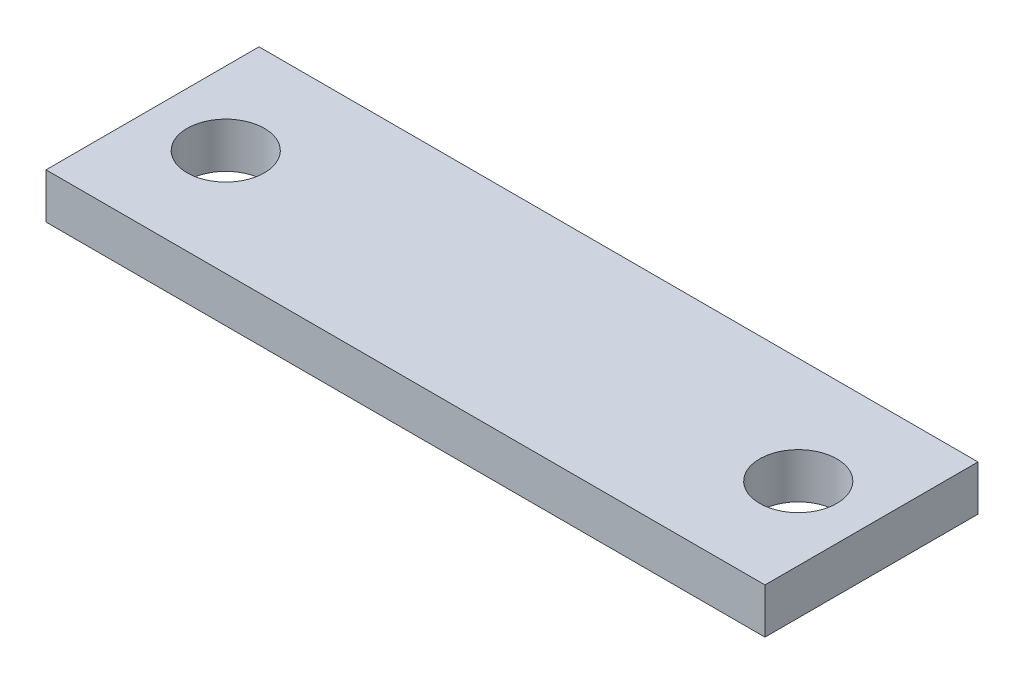
from build123d import *

# Parameters (mm, degrees)
SKETCH1_W           = 27
SKETCH1_H           = 8
SKETCH1_R           = 1.45
BOSS_EXTRUDE1_DEPTH = 1.7


with BuildPart() as part:
    # Sketch1 → Boss-Extrude1 (new body)
    with BuildSketch(Plane(origin=(0, 0, 0), x_dir=(1, 0, 0), z_dir=(0, 1, 0))):
        Rectangle(SKETCH1_W, SKETCH1_H)
        with Locations((-10.75, 0)):
            Circle(SKETCH1_R, mode=Mode.SUBTRACT)
        with Locations((10.75, 0)):
            Circle(SKETCH1_R, mode=Mode.SUBTRACT)
    extrude(amount=BOSS_EXTRUDE1_DEPTH)


solid = part.part
